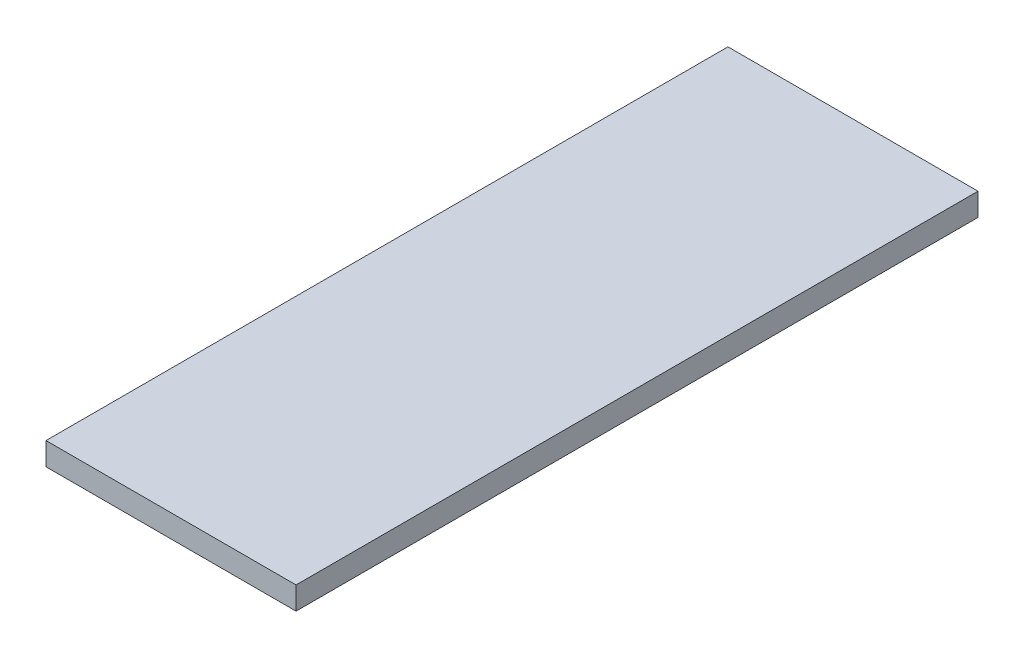
from build123d import *

# Parameters (mm, degrees)
SKETCH1_W           = 110
SKETCH1_H           = 300
BOSS_EXTRUDE1_DEPTH = 10


with BuildPart() as part:
    # Sketch1 → Boss-Extrude1 (new body)
    with BuildSketch(Plane(origin=(0, 0, 0), x_dir=(1, 0, 0), z_dir=(0, 1, 0))):
        Rectangle(SKETCH1_W, SKETCH1_H)
    extrude(amount=BOSS_EXTRUDE1_DEPTH)


solid = part.part
